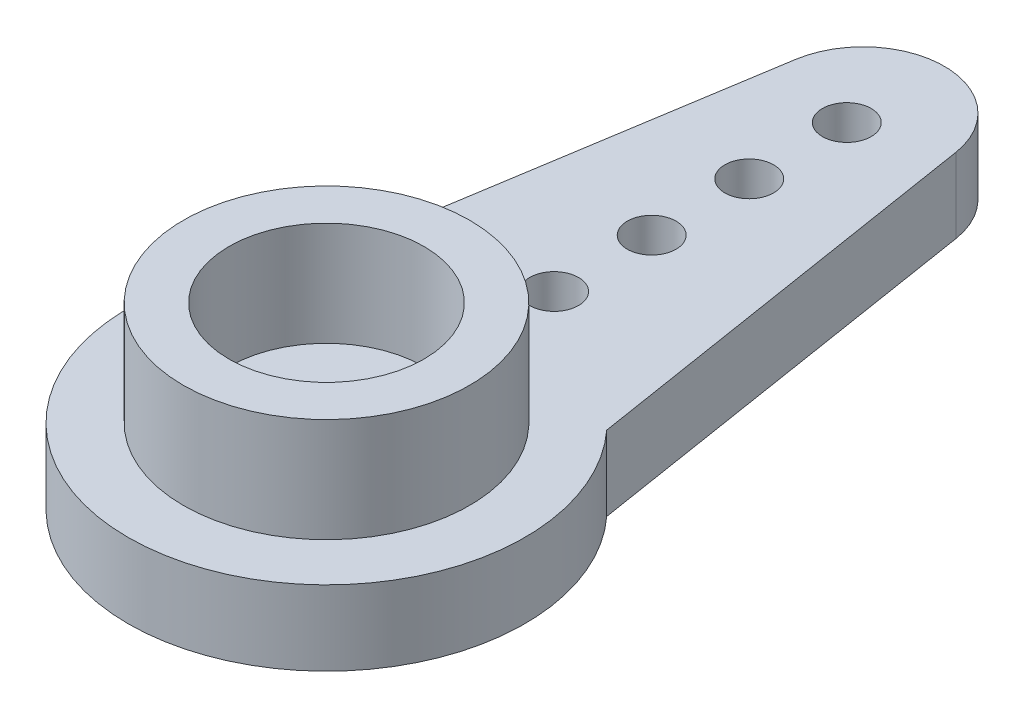
from build123d import *

# Parameters (mm, degrees)
SKETCH1_R           = 6.1
SKETCH1_R_2         = 1.5
BOSS_EXTRUDE1_DEPTH = 2.3
SKETCH2_R           = 4.4
SKETCH2_R_2         = 3
BOSS_EXTRUDE2_DEPTH = 3.2
SKETCH3_R           = 0.75
BOSS_EXTRUDE3_DEPTH = 2.3


with BuildPart() as part:
    # Sketch1 → Boss-Extrude1 (new body)
    with BuildSketch(Plane(origin=(0, 0, 0), x_dir=(1, 0, 0), z_dir=(0, 1, 0))):
        Circle(SKETCH1_R)
        Circle(SKETCH1_R_2, mode=Mode.SUBTRACT)
    extrude(amount=BOSS_EXTRUDE1_DEPTH)

    # Sketch2 → Boss-Extrude2 (add)
    with BuildSketch(Plane(origin=(0, 2.3, 0), x_dir=(1, 0, 0), z_dir=(0, 1, 0))):
        Circle(SKETCH2_R)
        Circle(SKETCH2_R_2, mode=Mode.SUBTRACT)
    extrude(amount=BOSS_EXTRUDE2_DEPTH)

    # Sketch3 → Boss-Extrude3 (add)
    with BuildSketch(Plane.XZ):
        with BuildLine():
            Line((-4.5, -4.118252056), (-2.468988638, -16.892549493))
            ThreePointArc((-2.468988638, -16.892549493), (0, -19), (2.468988638, -16.892549493))
            Line((2.468988638, -16.892549493), (4.5, -4.118252056))
            ThreePointArc((4.5, -4.118252056), (0, -6.1), (-4.5, -4.118252056))
        make_face()
        with Locations((0, -16)):
            Circle(SKETCH3_R, mode=Mode.SUBTRACT)
        with Locations((0, -13)):
            Circle(SKETCH3_R, mode=Mode.SUBTRACT)
        with Locations((0, -10)):
            Circle(SKETCH3_R, mode=Mode.SUBTRACT)
        with Locations((0, -7)):
            Circle(SKETCH3_R, mode=Mode.SUBTRACT)
    extrude(amount=-BOSS_EXTRUDE3_DEPTH)


solid = part.part
